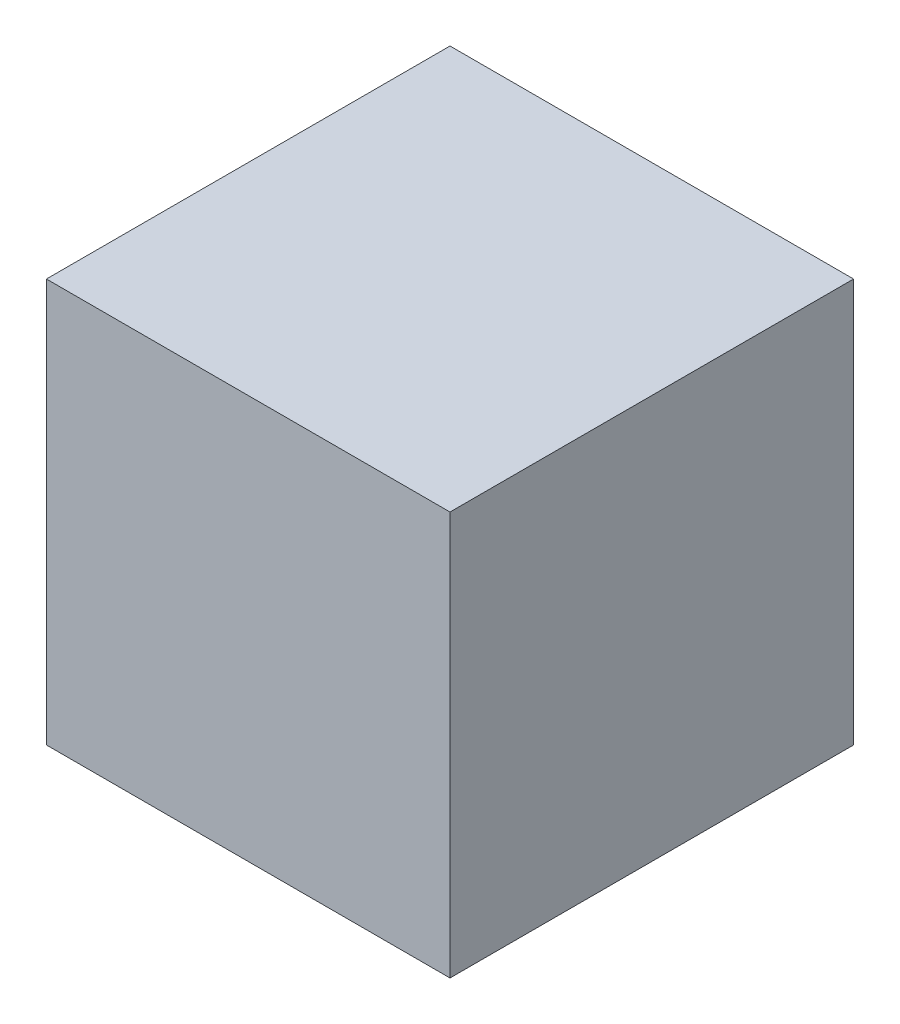
from build123d import *

# Parameters (mm, degrees)
SKETCH1_W           = 48
SKETCH1_H           = 48
BOSS_EXTRUDE1_DEPTH = 48


with BuildPart() as part:
    # Sketch1 → Boss-Extrude1 (new body)
    with BuildSketch(Plane(origin=(0, 0, 0), x_dir=(1, 0, 0), z_dir=(0, 1, 0))):
        Rectangle(SKETCH1_W, SKETCH1_H)
    extrude(amount=BOSS_EXTRUDE1_DEPTH)


solid = part.part
